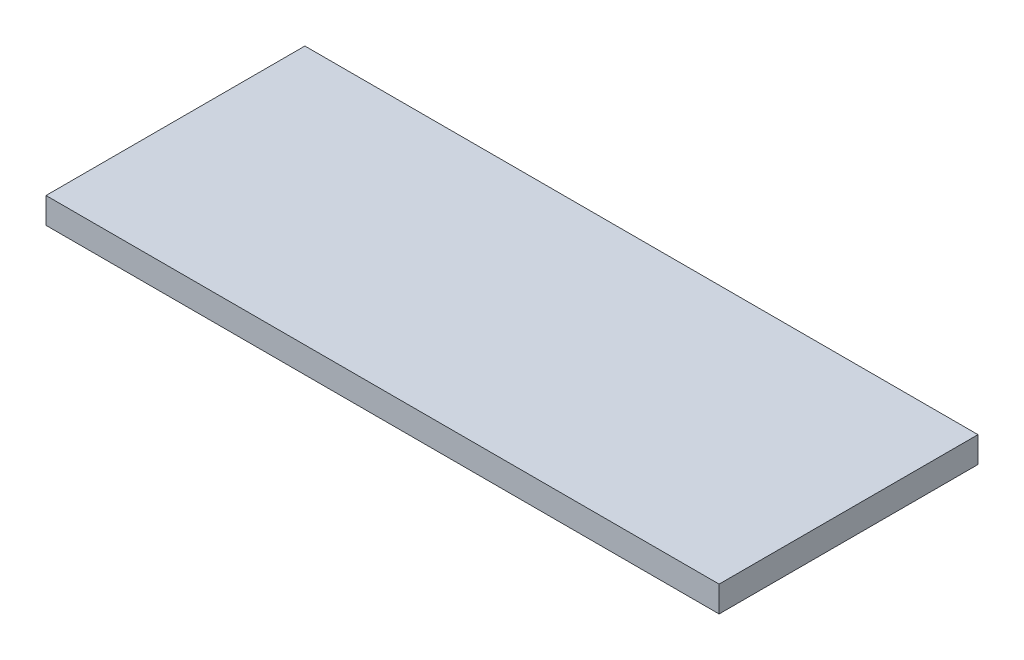
from build123d import *

# Parameters (mm, degrees)
SKETCH1_W           = 260
SKETCH1_H           = 100
BOSS_EXTRUDE1_DEPTH = 10


with BuildPart() as part:
    # Sketch1 → Boss-Extrude1 (new body)
    with BuildSketch(Plane(origin=(0, 0, 0), x_dir=(1, 0, 0), z_dir=(0, 1, 0))):
        Rectangle(SKETCH1_W, SKETCH1_H)
    extrude(amount=BOSS_EXTRUDE1_DEPTH)


solid = part.part
